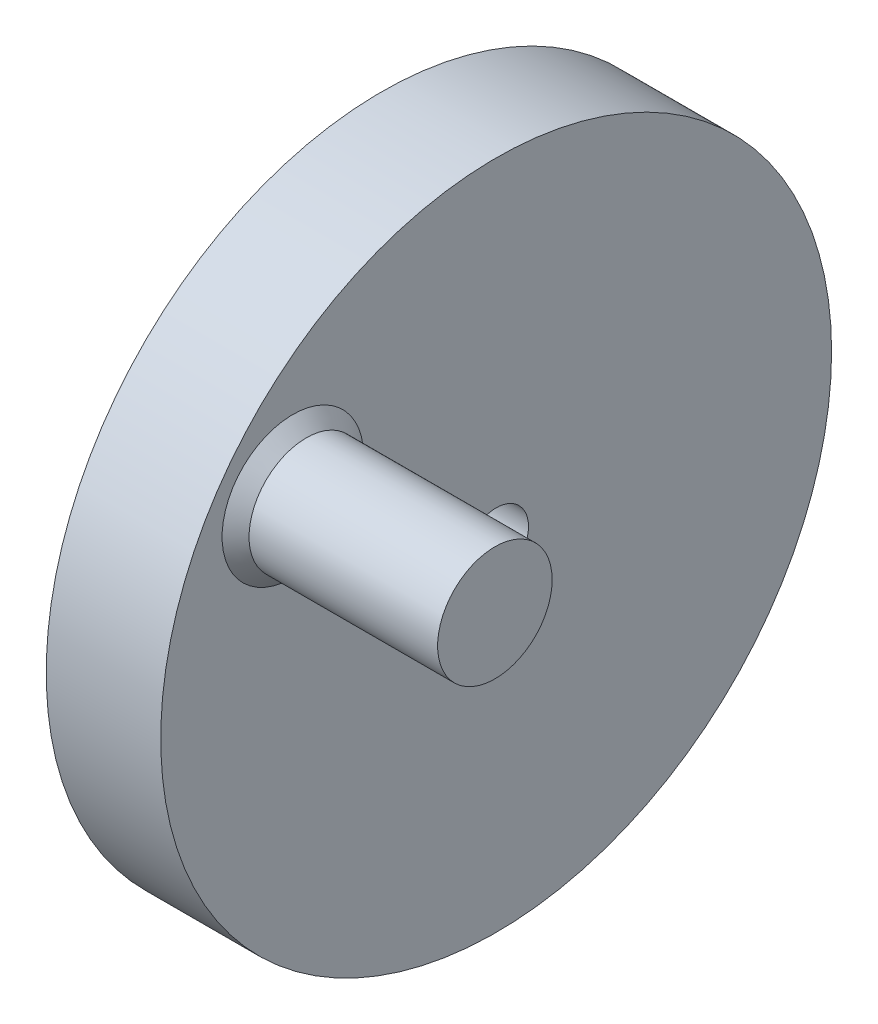
from build123d import *

# Parameters (mm, degrees)
CROQUIS1_R              = 24.9
CROQUIS1_R_2            = 2.4
SALIENTE_EXTRUIR1_DEPTH = 8.5
CROQUIS2_R              = 4.25
SALIENTE_EXTRUIR2_DEPTH = 15
CHAFL_N1_SIZE           = 1


with BuildPart() as part:
    # Croquis1 → Saliente-Extruir1 (new body)
    with BuildSketch(Plane(origin=(0, 0, 0), x_dir=(0, 0, -1), z_dir=(1, 0, 0))):
        Circle(CROQUIS1_R)
        Circle(CROQUIS1_R_2, mode=Mode.SUBTRACT)
    extrude(amount=SALIENTE_EXTRUIR1_DEPTH)

    # Croquis2 → Saliente-Extruir2 (add)
    with BuildSketch(Plane(origin=(8.5, 0, 0), x_dir=(0, 0, -1), z_dir=(1, 0, 0))):
        with Locations((-15.09387296, 10.696962141)):
            Circle(CROQUIS2_R)
    extrude(amount=SALIENTE_EXTRUIR2_DEPTH)

    # Chaflán1
    chafl_n1_edges = [part.edges().sort_by_distance(p)[0] for p in [
        (8.5, 10.696962141, 19.34387296),
    ]]
    chamfer(chafl_n1_edges, length=CHAFL_N1_SIZE)


solid = part.part
